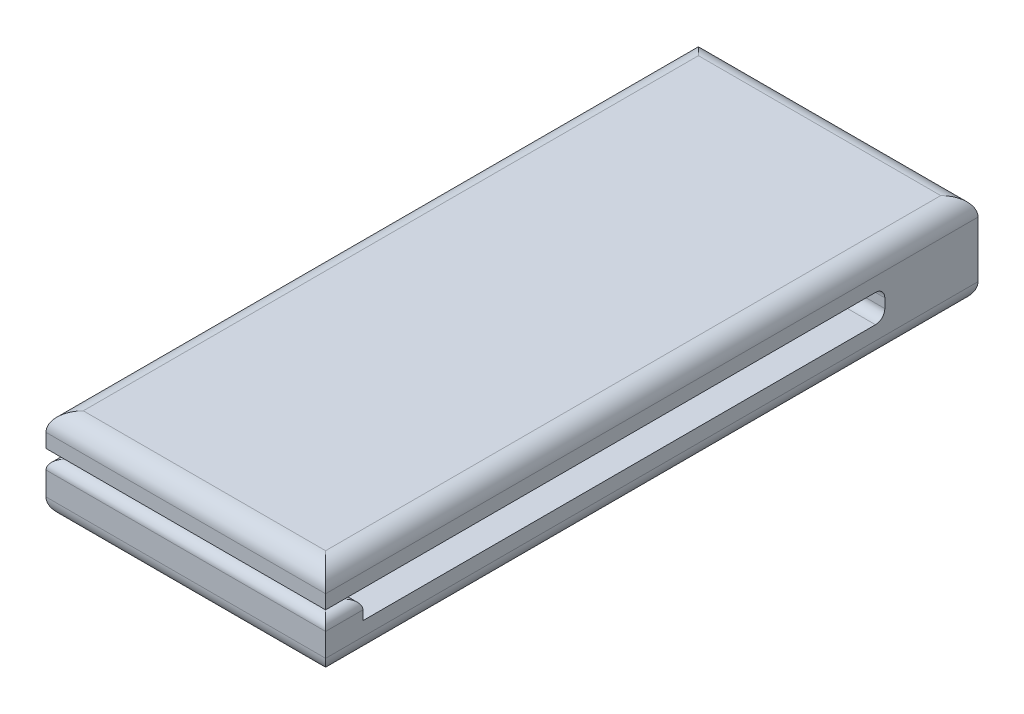
from build123d import *

# Parameters (mm, degrees)
SKETCH1_W           = 15
SKETCH1_H           = 35
BOSS_EXTRUDE1_DEPTH = 5
SKETCH4_W           = 15
SKETCH4_H           = 1.5
CUT_EXTRUDE1_DEPTH  = 30
FILLET1_R           = 1
FILLET2_R           = 1
FILLET3_R           = 0.5
FILLET4_R           = 0.5
SKETCH5_W           = 15
SKETCH5_H           = 2
BOSS_EXTRUDE2_DEPTH = 1.5
SKETCH8_W           = 2
SKETCH8_H           = 0.5
CUT_EXTRUDE3_DEPTH  = 15
FILLET5_R           = 0.5


with BuildPart() as part:
    # Sketch1 → Boss-Extrude1 (new body)
    with BuildSketch(Plane(origin=(0, 0, 0), x_dir=(1, 0, 0), z_dir=(0, 1, 0))):
        Rectangle(SKETCH1_W, SKETCH1_H)
    extrude(amount=BOSS_EXTRUDE1_DEPTH)

    # Sketch4 → Cut-Extrude1 (cut)
    with BuildSketch(Plane.XY.offset(17.5)):
        with Locations((0, 2.5)):
            Rectangle(SKETCH4_W, SKETCH4_H)
    extrude(amount=-CUT_EXTRUDE1_DEPTH, mode=Mode.SUBTRACT)

    # Fillet1
    fillet1_edges = [part.edges().sort_by_distance(p)[0] for p in [
        (-7.5, 5, 0),
        (0, 5, 17.5),
        (7.5, 5, 0),
        (0, 5, -17.5),
    ]]
    fillet(fillet1_edges, radius=FILLET1_R)

    # Fillet2
    fillet2_edges = [part.edges().sort_by_distance(p)[0] for p in [
        (0, 0, 17.5),
        (-7.5, 0, 0),
        (0, 0, -17.5),
        (7.5, 0, 0),
    ]]
    fillet(fillet2_edges, radius=FILLET2_R)

    # Fillet3
    fillet3_edges = [part.edges().sort_by_distance(p)[0] for p in [
        (0, 3.25, -12.5),
    ]]
    fillet(fillet3_edges, radius=FILLET3_R)

    # Fillet4
    fillet4_edges = [part.edges().sort_by_distance(p)[0] for p in [
        (0, 1.75, -12.5),
    ]]
    fillet(fillet4_edges, radius=FILLET4_R)

    # Sketch5 → Boss-Extrude2 (add)
    with BuildSketch(Plane(origin=(0, 1.75, 0), x_dir=(1, 0, 0), z_dir=(0, 1, 0))):
        with Locations((0, -16.5)):
            Rectangle(SKETCH5_W, SKETCH5_H)
    extrude(amount=BOSS_EXTRUDE2_DEPTH)

    # Sketch8 → Cut-Extrude3 (cut)
    with BuildSketch(Plane(origin=(7.5, 0, 0), x_dir=(0, 0, -1), z_dir=(1, 0, 0))):
        with Locations((-16.5, 3)):
            Rectangle(SKETCH8_W, SKETCH8_H)
    extrude(amount=-CUT_EXTRUDE3_DEPTH, mode=Mode.SUBTRACT)

    # Fillet5
    fillet5_edges = [part.edges().sort_by_distance(p)[0] for p in [
        (-7.5, 2.75, 16.5),
        (0, 2.75, 15.5),
        (0, 2.75, 17.5),
        (7.5, 2.75, 16.5),
    ]]
    fillet(fillet5_edges, radius=FILLET5_R)


solid = part.part
